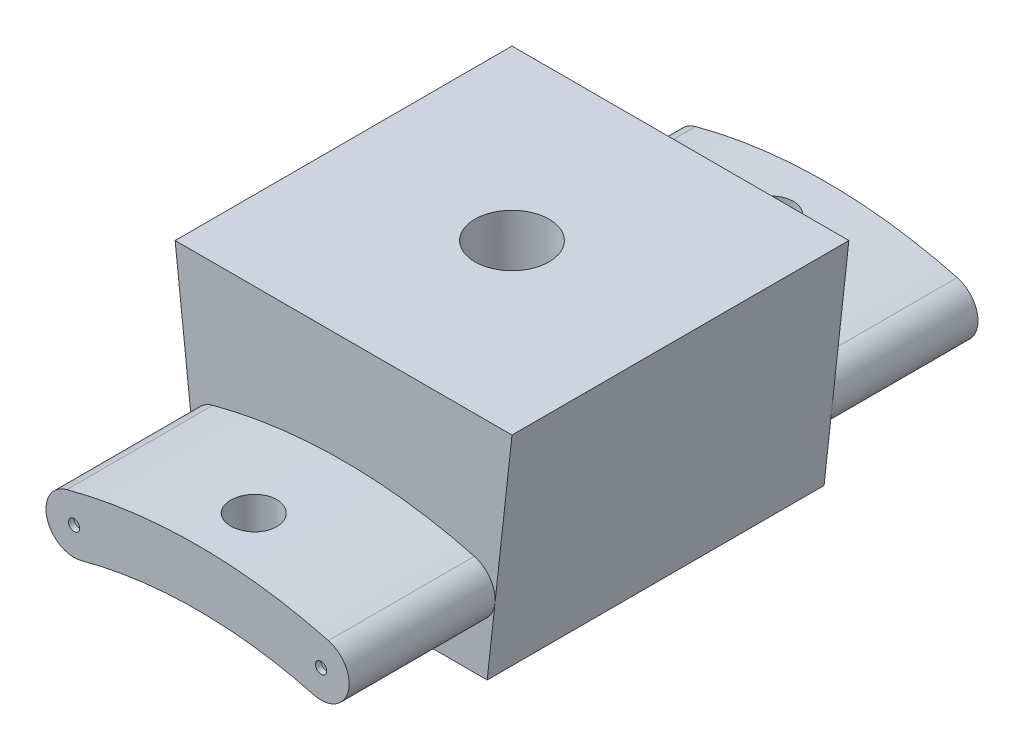
from build123d import *

# Parameters (mm, degrees)
SKETCH1_W             = 15
SKETCH1_H             = 15
BOSS_EXTRUDE1_DEPTH   = 10
SKETCH2_R             = 6
CUT_EXTRUDE1_DEPTH    = 4
SKETCH3_R             = 5
CUT_EXTRUDE2_DEPTH    = 3.5
BOSS_EXTRUDE2_DEPTH   = 6.5
M4_TAPPED_HOLE1_D     = 3.3
M4_TAPPED_HOLE1_DEPTH = 2.5
M2_5_TAPPED_HOLE1_D   = 2.05
SKETCH10_R            = 0.25
CUT_EXTRUDE3_DEPTH    = 0.25
CUT_EXTRUDE4_REACH    = 23.5


with BuildPart() as part:
    # Sketch1 → Boss-Extrude1 (new body)
    with BuildSketch(Plane(origin=(0, 0, 0), x_dir=(1, 0, 0), z_dir=(0, 1, 0))):
        Rectangle(SKETCH1_W, SKETCH1_H)
    extrude(amount=BOSS_EXTRUDE1_DEPTH)

    # Sketch2 → Cut-Extrude1 (cut)
    with BuildSketch(Plane.XZ):
        Circle(SKETCH2_R)
    extrude(amount=-CUT_EXTRUDE1_DEPTH, mode=Mode.SUBTRACT)

    # Sketch3 → Cut-Extrude2 (cut)
    with BuildSketch(Plane.XZ.offset(-4)):
        Circle(SKETCH3_R)
    extrude(amount=-CUT_EXTRUDE2_DEPTH, mode=Mode.SUBTRACT)

    # Sketch4 → Boss-Extrude2 (add)
    with BuildSketch(Plane.XY.offset(7.5)):
        with BuildLine():
            ThreePointArc((5.823428515, 4.483331092), (0, 5.25), (-5.823428515, 4.483331092))
            ThreePointArc((-5.823428515, 4.483331092), (-6.707311991, 2.952400002), (-5.176380902, 2.068516526))
            ThreePointArc((-5.176380902, 2.068516526), (0, 2.75), (5.176380902, 2.068516526))
            ThreePointArc((5.176380902, 2.068516526), (6.707311991, 2.952400002), (5.823428515, 4.483331092))
        make_face()
    boss_extrude2 = extrude(amount=BOSS_EXTRUDE2_DEPTH)

    # Mirror1: Boss-Extrude2 across plane
    add(boss_extrude2.mirror(Plane.XY))

    # M4 Tapped Hole1
    with Locations(Plane(origin=(0, 10, 0), x_dir=(1, 0, 0), z_dir=(0, 1, 0))):
        with Locations((0, 0)):
            Hole(M4_TAPPED_HOLE1_D / 2, depth=M4_TAPPED_HOLE1_DEPTH)

    # M2.5 Tapped Hole1 (through all)
    with Locations(Plane(origin=(0, 10, 0), x_dir=(1, 0, 0), z_dir=(0, 1, 0))):
        with Locations((0, 11.5), (0, -11.5)):
            Hole(M2_5_TAPPED_HOLE1_D / 2)

    # Sketch10 → Cut-Extrude3 (cut)
    with BuildSketch(Plane.XY.offset(14)):
        with Locations((-5.499904708, 3.275923809)):
            Circle(SKETCH10_R)
        with Locations((5.499904708, 3.275923809)):
            Circle(SKETCH10_R)
    extrude(amount=-CUT_EXTRUDE3_DEPTH, mode=Mode.SUBTRACT)

    # Sketch11 → Cut-Extrude4 (cut, up to next)
    with BuildSketch(Plane.XY.offset(7.5), mode=Mode.PRIVATE) as cut_extrude4_sk1:
        Polygon((-7.5, 10), (-6.395762797, 0), (-7.5, 0), align=None)
    cut_extrude4_tool1 = extrude(cut_extrude4_sk1.sketch, amount=-CUT_EXTRUDE4_REACH, mode=Mode.PRIVATE) & part.part
    add(cut_extrude4_tool1.solids().sort_by_distance((-7.131921, 3.333333, 7.5))[0], mode=Mode.SUBTRACT)
    # Sketch11 → Cut-Extrude4 (cut, up to next)
    with BuildSketch(Plane.XY.offset(7.5), mode=Mode.PRIVATE) as cut_extrude4_sk2:
        Polygon((7.5, 10), (6.395762797, 0), (7.5, 0), align=None)
    cut_extrude4_tool2 = extrude(cut_extrude4_sk2.sketch, amount=-CUT_EXTRUDE4_REACH, mode=Mode.PRIVATE) & part.part
    add(cut_extrude4_tool2.solids().sort_by_distance((7.131921, 3.333333, 7.5))[0], mode=Mode.SUBTRACT)


solid = part.part
